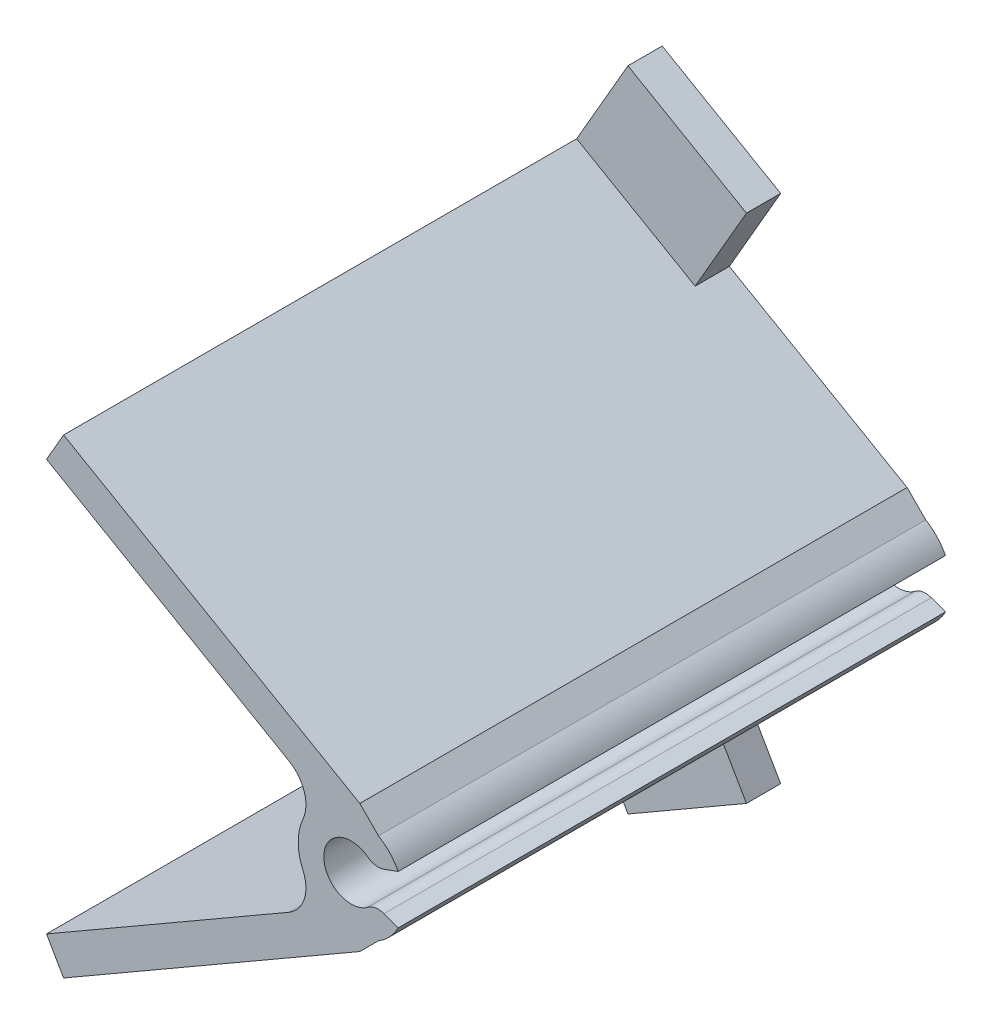
from build123d import *

# Parameters (mm, degrees)
BOSS_EXTRUDE2_DEPTH = 16
BOSS_EXTRUDE3_DEPTH = 16
FILLET9_R           = 0.5
BOSS_EXTRUDE4_DEPTH = 1
FILLET10_R          = 1


with BuildPart() as part:
    # Sketch5 → Boss-Extrude2 (new body)
    with BuildSketch(Plane(origin=(4.228476288, 0, 0), x_dir=(1, 0, 0), z_dir=(0, 0, 1))):
        with BuildLine():
            Line((-3.568997542, 0.452866188), (-2.852532713, 0.71363806))
            ThreePointArc((-2.852532713, 0.71363806), (-5.778476288, 0), (-2.852532713, -0.71363806))
            Line((-2.852532713, -0.71363806), (-3.568997542, -0.452866188))
            ThreePointArc((-3.568997542, -0.452866188), (-5.028476288, 0), (-3.568997542, 0.452866188))
        make_face()
    extrude(amount=BOSS_EXTRUDE2_DEPTH)

    # Sketch6 → Boss-Extrude3 (add)
    with BuildSketch(Plane.XY.offset(16)):
        Polygon((-8.907406692, 6.008719055), (-8.407406692, 6.874744459), (0.252847346, 1.874744459), (1.327591805, 0.8), (0.114359354, 0.8), align=None)
        Polygon((0.252847346, -1.874744459), (1.327591805, -0.8), (0.114359354, -0.8), (-8.907406692, -6.008719055), (-8.407406692, -6.874744459), align=None)
    extrude(amount=-BOSS_EXTRUDE3_DEPTH)

    # Fillet9
    fillet9_edges = [part.edges().sort_by_distance(p)[0] for p in [
        (0.659478746, -0.452866188, 8),
        (0.659478746, 0.452866188, 8),
    ]]
    fillet(fillet9_edges, radius=FILLET9_R)

    # Sketch7 → Boss-Extrude4 (add)
    with BuildSketch(Plane(origin=(0, 0, 0), x_dir=(-1, 0, 0), z_dir=(0, 0, -1))):
        Polygon((8.407406692, 6.874744459), (4.943305077, 4.874744459), (3.443305077, 7.47282067), (6.907406692, 9.47282067), align=None)
        Polygon((6.907406692, -9.47282067), (3.443305077, -7.47282067), (4.943305077, -4.874744459), (8.407406692, -6.874744459), align=None)
        Polygon((8.907406692, 6.008719055), (7.175355885, 5.008719055), (7.675355885, 4.142693652), (9.407406692, 5.142693652), align=None)
        Polygon((9.407406692, -5.142693652), (7.675355885, -4.142693652), (7.175355885, -5.008719055), (8.907406692, -6.008719055), align=None)
    extrude(amount=-BOSS_EXTRUDE4_DEPTH)

    # Fillet10
    fillet10_edges = [part.edges().sort_by_distance(p)[0] for p in [
        (-0.799734012, 1.327752051, 8),
        (-0.799734012, -1.327752051, 8),
    ]]
    fillet(fillet10_edges, radius=FILLET10_R)


solid = part.part
